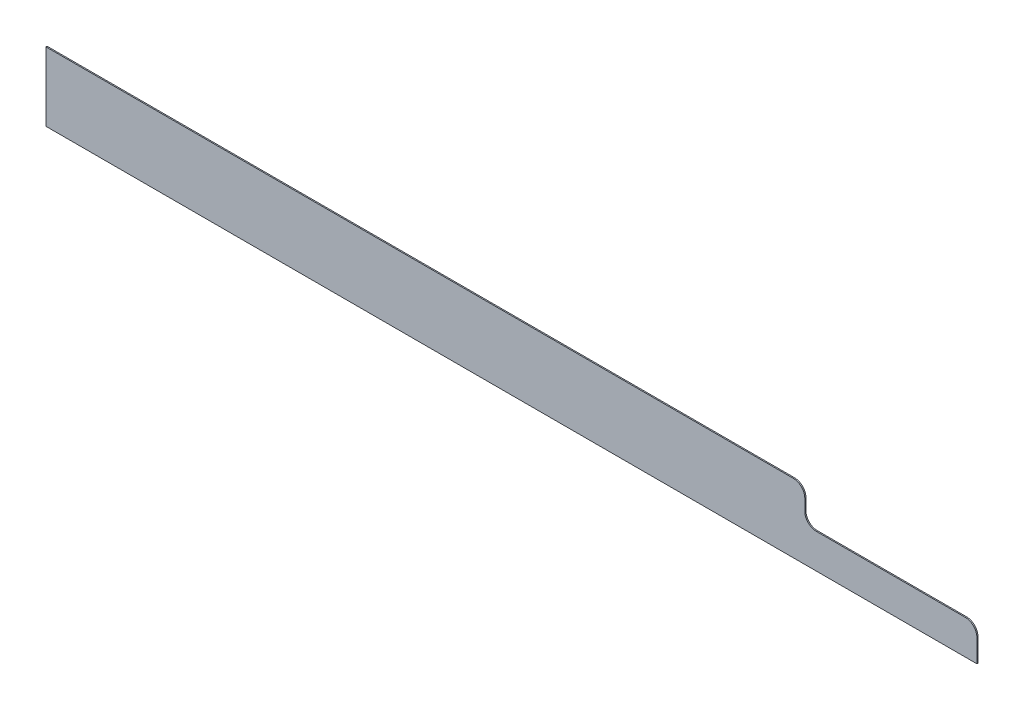
from build123d import *

# Parameters (mm, degrees)
BOSS_EXTRU_1_DEPTH = 2
CONG_1_R           = 20


with BuildPart() as part:
    # Esquisse1 → Boss.-Extru.1 (new body)
    with BuildSketch(Plane.XY):
        Polygon((653.5, 120), (669.5, 120), (669.5, 60), (969.5, 60), (969.5, 0), (653.5, 0), (-653.5, 0), (-653.5, 120), align=None)
    extrude(amount=BOSS_EXTRU_1_DEPTH)

    # Congé1
    cong_1_edges = [part.edges().sort_by_distance(p)[0] for p in [
        (669.5, 120, 1),
        (669.5, 60, 1),
        (969.5, 60, 1),
    ]]
    fillet(cong_1_edges, radius=CONG_1_R)


solid = part.part
